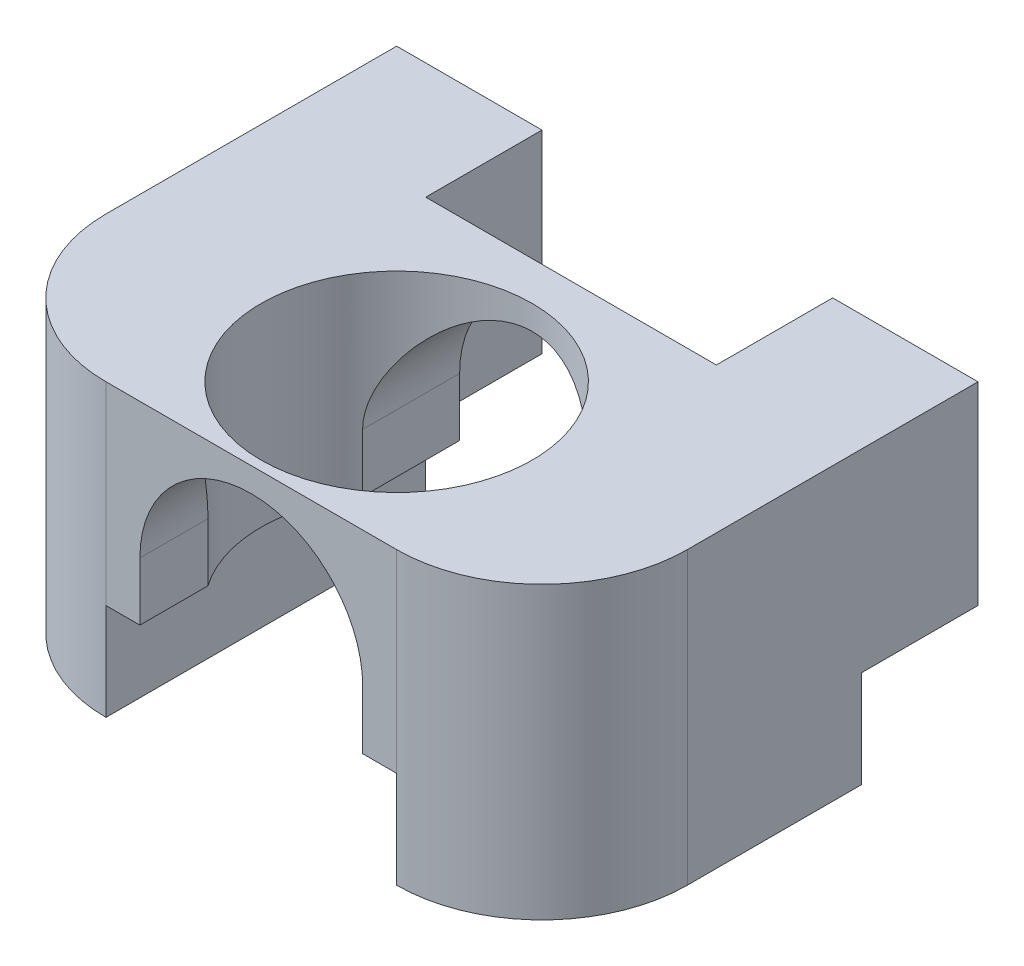
from build123d import *

# Parameters (mm, degrees)
BOSS_EXTRUDE1_DEPTH = 33
SKETCH3_R           = 14
CUT_EXTRUDE1_DEPTH  = 21
SKETCH4_W           = 15
SKETCH4_H           = 45
BOSS_EXTRUDE2_DEPTH = 20
SKETCH7_W           = 15
SKETCH7_H           = 33
BOSS_EXTRUDE3_DEPTH = 10
FILLET1_R           = 15


with BuildPart() as part:
    # Sketch2 → Boss-Extrude1 (new body)
    with BuildSketch(Plane.XY):
        with BuildLine():
            Line((11.5, 0), (11.5, -6))
            Line((11.5, -6), (15, -6))
            Line((15, -6), (15, 14))
            Line((15, 14), (-15, 14))
            Line((-15, 14), (-15, -6))
            Line((-15, -6), (-11.5, -6))
            Line((-11.5, -6), (-11.5, 0))
            ThreePointArc((-11.5, 0), (0, 11.5), (11.5, 0))
        make_face()
    extrude(amount=BOSS_EXTRUDE1_DEPTH)

    # Sketch3 → Cut-Extrude1 (cut, through all)
    with BuildSketch(Plane(origin=(0, 14, 0), x_dir=(1, 0, 0), z_dir=(0, 1, 0))):
        with Locations((0, -18)):
            Circle(SKETCH3_R)
    extrude(amount=-CUT_EXTRUDE1_DEPTH, mode=Mode.SUBTRACT)

    # Sketch4 → Boss-Extrude2 (add)
    with BuildSketch(Plane(origin=(0, 14, 0), x_dir=(1, 0, 0), z_dir=(0, 1, 0))):
        with Locations((22.5, -10.5)):
            Rectangle(SKETCH4_W, SKETCH4_H)
    boss_extrude2 = extrude(amount=-BOSS_EXTRUDE2_DEPTH)

    # Sketch6 → M5x0.8 Tapped Hole1 (revolve, cut)
    with BuildSketch(Plane(origin=(24, -6, -6), x_dir=(0, 0, -1), z_dir=(1, 0, 0))):
        Polygon((0, 0), (0, 13.6618073), (2.1, 12.4), (2.1, 0), align=None)
    m5x0_8_tapped_hole1 = revolve(axis=Axis((24, -12.35, -6), (0, 1, 0)), mode=Mode.SUBTRACT)

    # Sketch7 → Boss-Extrude3 (add)
    with BuildSketch(Plane.XZ.offset(6)):
        with Locations((22.5, 16.5)):
            Rectangle(SKETCH7_W, SKETCH7_H)
    boss_extrude3 = extrude(amount=BOSS_EXTRUDE3_DEPTH)

    # Mirror1: Boss-Extrude2, M5x0.8 Tapped Hole1, Boss-Extrude3 across plane
    add(boss_extrude2.mirror(Plane(origin=(0, 0, 0), x_dir=(0, 0, 1), z_dir=(1, 0, 0))))
    add(m5x0_8_tapped_hole1.mirror(Plane(origin=(0, 0, 0), x_dir=(0, 0, 1), z_dir=(1, 0, 0))), mode=Mode.SUBTRACT)
    add(boss_extrude3.mirror(Plane(origin=(0, 0, 0), x_dir=(0, 0, 1), z_dir=(1, 0, 0))))

    # Fillet1
    fillet1_edges = [part.edges().sort_by_distance(p)[0] for p in [
        (30, -1, 33),
        (-30, -1, 33),
    ]]
    fillet(fillet1_edges, radius=FILLET1_R)


solid = part.part
